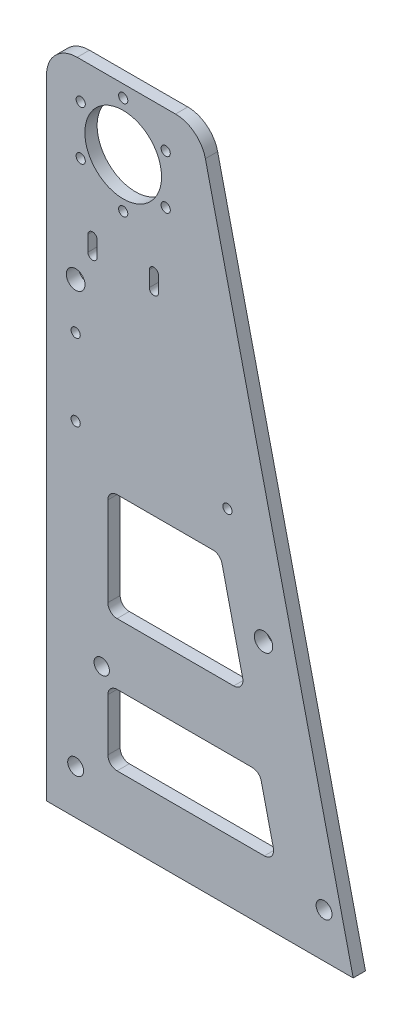
from build123d import *

# Parameters (mm, degrees)
ESBO_O1_R                = 12.5
ESBO_O1_R_2              = 1.5
ESBO_O1_R_3              = 2.5
RESSALTO_EXTRUS_O2_DEPTH = 4
FILETE1_R                = 10
ESBO_O2_R                = 1.5
ESBO_O2_R_2              = 2.6
ESBO_O2_R_3              = 3.05
CORTE_EXTRUS_O1_DEPTH    = 5
ESBO_O3_R                = 3
CORTE_EXTRUS_O2_DEPTH    = 5


with BuildPart() as part:
    # Esboço1 → Ressalto-extrusão2 (new body)
    with BuildSketch(Plane.XY):
        Polygon((0, 0), (0, 215), (50, 215), (100, 0), align=None)
        with Locations((25, 195)):
            Circle(ESBO_O1_R, mode=Mode.SUBTRACT)
        with Locations((25, 211)):
            Circle(ESBO_O1_R_2, mode=Mode.SUBTRACT)
        with Locations((38.856406461, 203)):
            Circle(ESBO_O1_R_2, mode=Mode.SUBTRACT)
        with Locations((38.856406461, 187)):
            Circle(ESBO_O1_R_2, mode=Mode.SUBTRACT)
        with Locations((25, 179)):
            Circle(ESBO_O1_R_2, mode=Mode.SUBTRACT)
        with Locations((11.143593539, 187)):
            Circle(ESBO_O1_R_2, mode=Mode.SUBTRACT)
        with Locations((11.143593539, 203)):
            Circle(ESBO_O1_R_2, mode=Mode.SUBTRACT)
        with Locations((18, 47)):
            Circle(ESBO_O1_R_3, mode=Mode.SUBTRACT)
        with BuildLine():
            Line((20, 95), (20, 66))
            ThreePointArc((20, 66), (20.878679656, 63.878679656), (23, 63))
            Line((23, 63), (61.03739436, 63))
            ThreePointArc((61.03739436, 63), (63.386715693, 64.134339454), (63.959418441, 66.679540484))
            Line((63.959418441, 66.679540484), (57.215232395, 95.679540484))
            ThreePointArc((57.215232395, 95.679540484), (56.15886886, 97.349321333), (54.293208314, 98))
            Line((54.293208314, 98), (23, 98))
            ThreePointArc((23, 98), (20.878679656, 97.121320344), (20, 95))
        make_face(mode=Mode.SUBTRACT)
        with BuildLine():
            Line((20, 40), (20, 23))
            ThreePointArc((20, 23), (20.878679656, 20.878679656), (23, 20))
            Line((23, 20), (71.03739436, 20))
            ThreePointArc((71.03739436, 20), (73.386715693, 21.134339454), (73.959418441, 23.679540484))
            Line((73.959418441, 23.679540484), (70.005930069, 40.679540484))
            ThreePointArc((70.005930069, 40.679540484), (68.949566534, 42.349321333), (67.083905988, 43))
            Line((67.083905988, 43), (23, 43))
            ThreePointArc((23, 43), (20.878679656, 42.121320344), (20, 40))
        make_face(mode=Mode.SUBTRACT)
    extrude(amount=RESSALTO_EXTRUS_O2_DEPTH)

    # Filete1
    filete1_edges = [part.edges().sort_by_distance(p)[0] for p in [
        (0, 215, 2),
        (50, 215, 2),
    ]]
    fillet(filete1_edges, radius=FILETE1_R)

    # Esboço2 → Corte-extrusão1 (cut, through all)
    with BuildSketch(Plane.XY.offset(4)):
        with Locations((9.5, 137)):
            Circle(ESBO_O2_R)
        with Locations((90.5, 14.5)):
            Circle(ESBO_O2_R_2)
        with Locations((9.5, 112)):
            Circle(ESBO_O2_R)
        with Locations((9.5, 152)):
            Circle(ESBO_O2_R_3)
        with Locations((59, 112)):
            Circle(ESBO_O2_R)
        with Locations((9.5, 14.5)):
            Circle(ESBO_O2_R_2)
        with BuildLine():
            Line((13.5, 161.71), (13.5, 166.71))
            ThreePointArc((13.5, 166.71), (15, 168.21), (16.5, 166.71))
            Line((16.5, 166.71), (16.5, 161.71))
            ThreePointArc((16.5, 161.71), (15, 160.21), (13.5, 161.71))
        make_face()
        with BuildLine():
            Line((33.5, 161.71), (33.5, 166.71))
            ThreePointArc((33.5, 166.71), (35, 168.21), (36.5, 166.71))
            Line((36.5, 166.71), (36.5, 161.71))
            ThreePointArc((36.5, 161.71), (35, 160.21), (33.5, 161.71))
        make_face()
    extrude(amount=-CORTE_EXTRUS_O1_DEPTH, mode=Mode.SUBTRACT)

    # Esboço3 → Corte-extrusão2 (cut, through all)
    with BuildSketch(Plane.XY.offset(4)):
        with Locations((70.759810426, 80.398555206)):
            Circle(ESBO_O3_R)
    extrude(amount=-CORTE_EXTRUS_O2_DEPTH, mode=Mode.SUBTRACT)


solid = part.part
